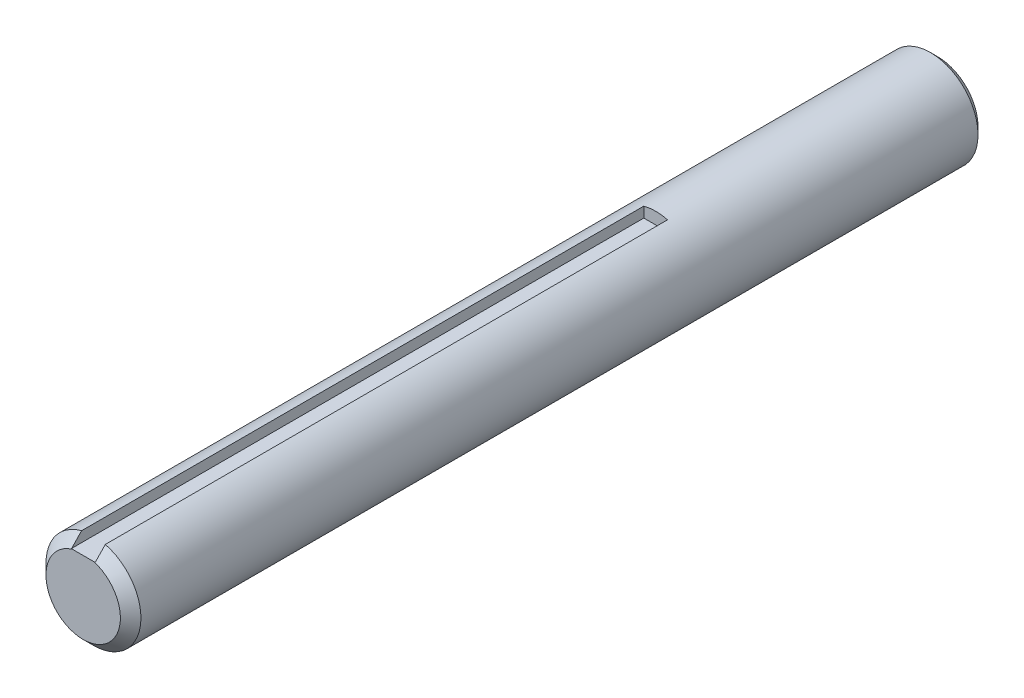
from build123d import *

# Parameters (mm, degrees)
SKETCH1_R           = 6.35
EXTRUDE1_DEPTH      = 76.2
CHAMFER1_SIZE       = 0.9525
SKETCH3_W           = 3.175
SKETCH3_H           = 1.5875
EXTRUDE2_DEPTH      = 77.727341932
EXTRUDE2_DEPTH_BACK = 38.481
CHAMFER2_SIZE       = 1.373522526


with BuildPart() as part:
    # Sketch1 → Extrude1 (new, symmetric)
    with BuildSketch(Plane.XY):
        with Locations(Location((0, 0, 0), (0, 0, 180))):
            Circle(SKETCH1_R)
    extrude(amount=EXTRUDE1_DEPTH, both=True)

    # Chamfer1
    chamfer1_edges = [part.edges().sort_by_distance(p)[0] for p in [
        (6.35, 0, -76.2),
        (6.35, 0, 76.2),
    ]]
    chamfer(chamfer1_edges, length=CHAMFER1_SIZE)

    # Sketch3 → Extrude2 (cut, two sides)
    with BuildSketch(Plane.XY) as extrude2_sk:
        with Locations((0, 5.55625)):
            Rectangle(SKETCH3_W, SKETCH3_H)
    extrude(amount=EXTRUDE2_DEPTH, mode=Mode.SUBTRACT)
    extrude(extrude2_sk.sketch, amount=-EXTRUDE2_DEPTH_BACK, mode=Mode.SUBTRACT)

    # SurfaceCut1
    split(bisect_by=Plane.XY.offset(38.1), keep=Keep.BOTTOM)

    # Chamfer2
    chamfer2_edges = [part.edges().sort_by_distance(p)[0] for p in [
        (3.888564967, -5.020115786, 38.1),
    ]]
    chamfer(chamfer2_edges, length=CHAMFER2_SIZE)


solid = part.part
